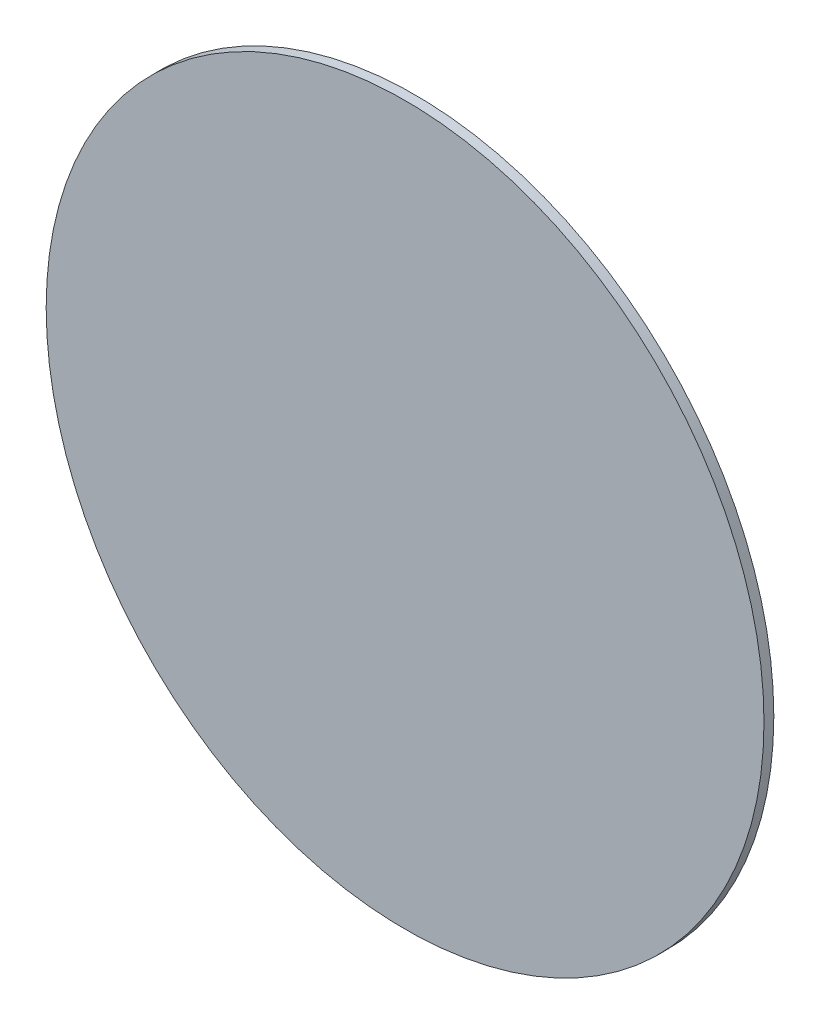
from build123d import *

# Parameters (mm, degrees)
EXTRUDE1_START = 19.05
SKETCH1_R      = 115.8875
EXTRUDE1_DEPTH = 3.175


with BuildPart() as part:
    # Sketch1 → Extrude1 (new body)
    with BuildSketch(Plane.XY.offset(EXTRUDE1_START)):
        with Locations((0, 33.3375)):
            Circle(SKETCH1_R)
    extrude(amount=EXTRUDE1_DEPTH)


solid = part.part
